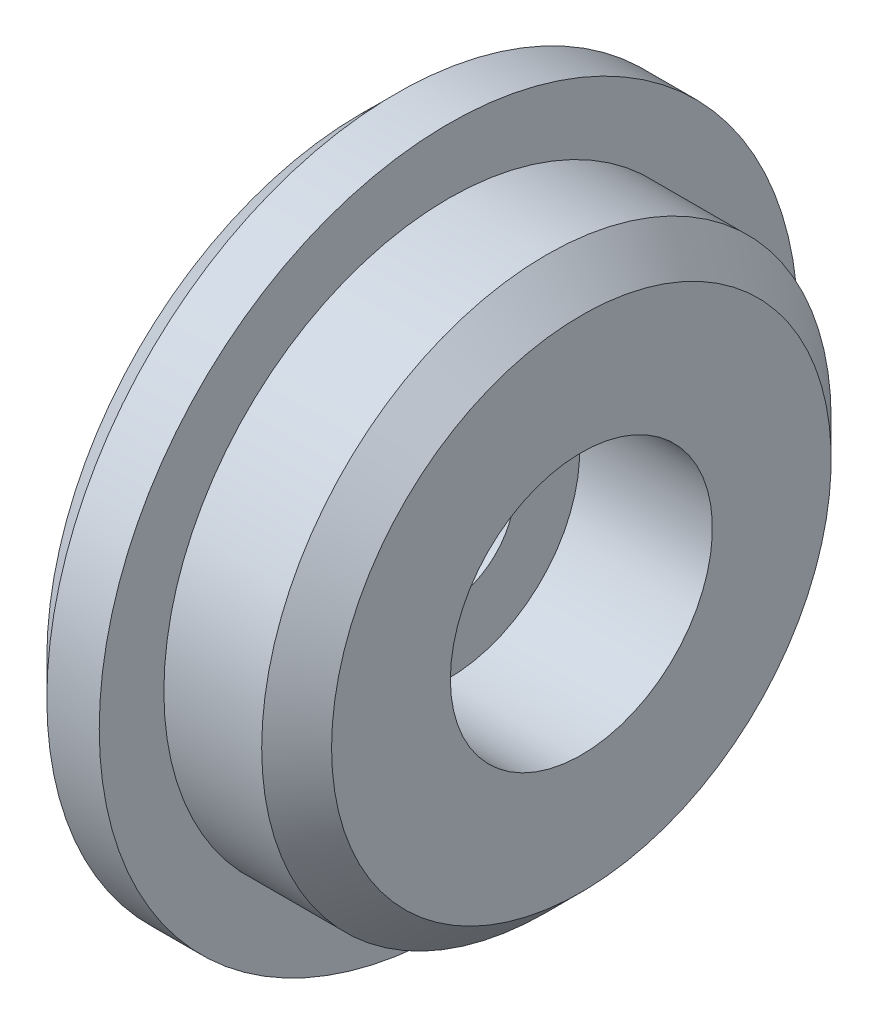
from build123d import *

# Parameters (mm, degrees)
CHAMFER1_SIZE = 0.1


with BuildPart() as part:
    # Sketch1 → Revolve1 (revolve)
    with BuildSketch(Plane.XY):
        Polygon((0, 0.19), (0, 1), (0.25, 1), (0.25, 0.815), (0.63, 0.815), (0.63, 0.375), (0.25, 0.375), (0.25, 0.19), align=None)
    revolve(axis=Axis((-1.719172551, 0, 0), (1, 0, 0)))

    # Chamfer1
    chamfer1_edges = [part.edges().sort_by_distance(p)[0] for p in [
        (0.63, -0.815, 0),
        (0, -1, 0),
    ]]
    chamfer(chamfer1_edges, length=CHAMFER1_SIZE)


solid = part.part
